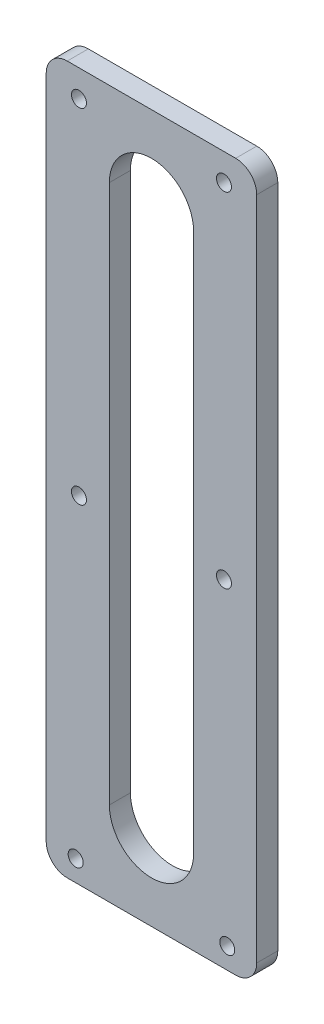
from build123d import *

# Parameters (mm, degrees)
SKETCH1_W             = 31.75
SKETCH1_H             = 106.68
BOSS_EXTRUDE1_DEPTH   = 3.175
FILLET1_R             = 3.175
F_4_40_TAPPED_HOLE1_D = 2.2606


with BuildPart() as part:
    # Sketch1 → Boss-Extrude1 (new body)
    with BuildSketch(Plane.XY.offset(3.175)):
        with Locations((15.875, 53.34)):
            Rectangle(SKETCH1_W, SKETCH1_H)
        with BuildLine():
            Line((22.225, 93.98), (22.225, 12.7))
            ThreePointArc((22.225, 12.7), (15.875, 6.35), (9.525, 12.7))
            Line((9.525, 12.7), (9.525, 93.98))
            ThreePointArc((9.525, 93.98), (15.875, 100.33), (22.225, 93.98))
        make_face(mode=Mode.SUBTRACT)
    extrude(amount=-BOSS_EXTRUDE1_DEPTH)

    # Fillet1
    fillet1_edges = [part.edges().sort_by_distance(p)[0] for p in [
        (0, 0, 1.5875),
        (0, 106.68, 1.5875),
        (31.75, 106.68, 1.5875),
        (31.75, 0, 1.5875),
    ]]
    fillet(fillet1_edges, radius=FILLET1_R)

    # #4-40 Tapped Hole1 (through all)
    with Locations(Plane(origin=(0, 0, 0), x_dir=(-1, 0, 0), z_dir=(0, 0, -1))):
        with Locations((-4.445, 3.175), (-4.9403, 50.8), (-27.305, 3.175), (-26.8097, 50.8), (-26.8097, 102.616), (-4.9403, 102.616)):
            Hole(F_4_40_TAPPED_HOLE1_D / 2)


solid = part.part
